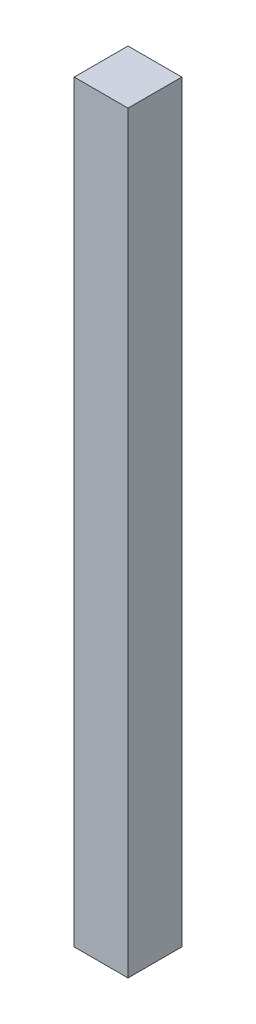
from build123d import *

# Parameters (mm, degrees)
SKETCH1_W           = 40
SKETCH1_H           = 40
BOSS_EXTRUDE1_DEPTH = 560


with BuildPart() as part:
    # Sketch1 → Boss-Extrude1 (new body)
    with BuildSketch(Plane(origin=(0, 0, 0), x_dir=(1, 0, 0), z_dir=(0, 1, 0))):
        Rectangle(SKETCH1_W, SKETCH1_H)
    extrude(amount=BOSS_EXTRUDE1_DEPTH)


solid = part.part
